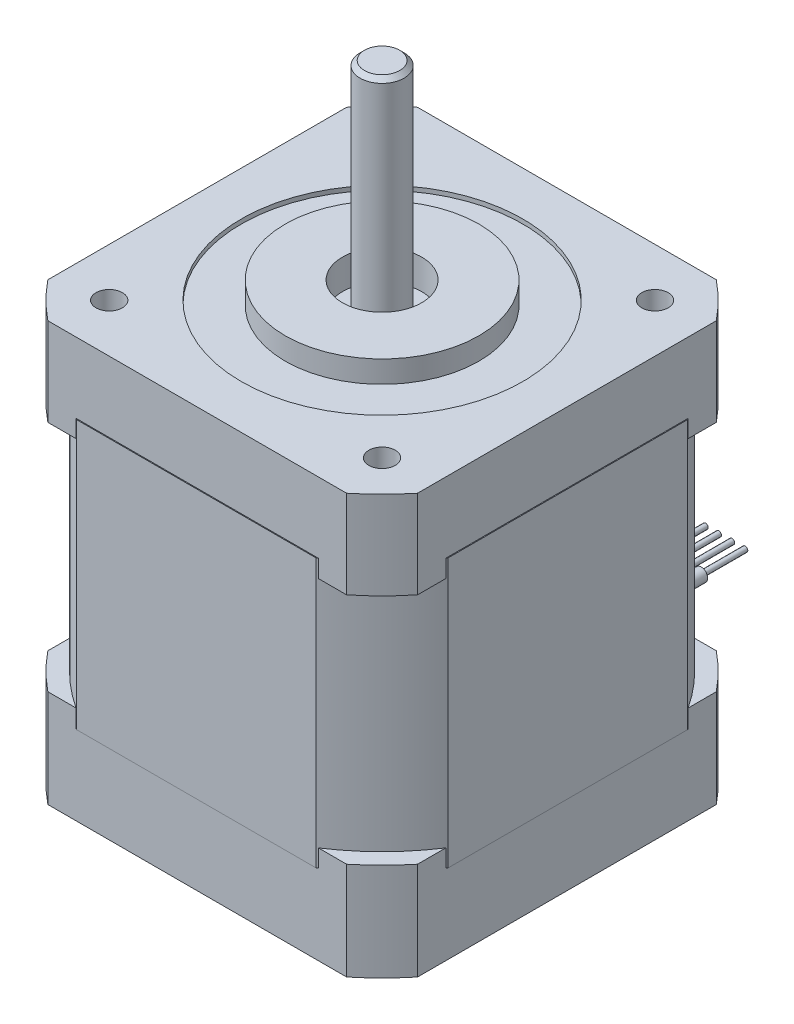
from build123d import *

# Parameters (mm, degrees)
SKETCH_2_R          = 1.5
EXTRUDE_2_DEPTH     = 8
SKETCH_3_R          = 16
CUT_EXTRUDE_1_DEPTH = 0.5
SKETCH_4_R          = 11
EXTRUDE_3_DEPTH     = 2.5
SKETCH_5_R          = 4.5
CUT_EXTRUDE_2_DEPTH = 3.4
SKETCH_6_R          = 2.5
EXTRUDE_4_DEPTH     = 25
CHAMFER_2_SIZE      = 0.5
SKETCH_2_2_R        = 1.5
EXTRUDE_5_DEPTH     = 2
SKETCH_7_R          = 1.5
EXTRUDE_6_DEPTH     = 30.5
SKETCH_8_R          = 1.5
EXTRUDE_8_DEPTH     = 2
SKETCH_8_3_R        = 1.5
EXTRUDE_9_DEPTH     = 9.1
SKETCH_9_R          = 3.5
SKETCH_9_R_2        = 3
CUT_EXTRUDE_3_DEPTH = 3.5
SKETCH_10_R         = 2.5
EXTRUDE_10_DEPTH    = 3
SKETCH_10_2_R       = 2.5
EXTRUDE_11_DEPTH    = 39
FILLET_2_R          = 2
FILLET_3_R          = 2
FILLET_4_R          = 2
FILLET_5_R          = 2
CUT_EXTRUDE_4_DEPTH = 3.5
CUT_EXTRUDE_5_DEPTH = 2
SKETCH_13_R         = 0.74
EXTRUDE_16_DEPTH    = 15
SKETCH_14_R         = 0.3
EXTRUDE_17_DEPTH    = 5


with BuildPart() as part:
    # Sketch 2 → Extrude 2 (new body)
    with BuildSketch(Plane(origin=(0, 0, 0), x_dir=(1, 0, 0), z_dir=(0, 1, 0))):
        with BuildLine():
            Line((16.970562748, 21), (-16.970562748, 21))
            ThreePointArc((-16.970562748, 21), (-19.091883092, 19.091883092), (-21, 16.970562748))
            Line((-21, 16.970562748), (-21, -16.970562748))
            ThreePointArc((-21, -16.970562748), (-19.091883092, -19.091883092), (-16.970562748, -21))
            Line((-16.970562748, -21), (16.970562748, -21))
            ThreePointArc((16.970562748, -21), (19.091883092, -19.091883092), (21, -16.970562748))
            Line((21, -16.970562748), (21, 16.970562748))
            ThreePointArc((21, 16.970562748), (19.091883092, 19.091883092), (16.970562748, 21))
        make_face()
        with Locations((-15.5, 15.5)):
            Circle(SKETCH_2_R, mode=Mode.SUBTRACT)
        with Locations((15.5, 15.5)):
            Circle(SKETCH_2_R, mode=Mode.SUBTRACT)
        with Locations((15.5, -15.5)):
            Circle(SKETCH_2_R, mode=Mode.SUBTRACT)
        with Locations((-15.5, -15.5)):
            Circle(SKETCH_2_R, mode=Mode.SUBTRACT)
    extrude(amount=EXTRUDE_2_DEPTH)

    # Sketch 3 → Cut-Extrude 1 (cut)
    with BuildSketch(Plane(origin=(0, 8, 0), x_dir=(1, 0, 0), z_dir=(0, 1, 0))):
        Circle(SKETCH_3_R)
    extrude(amount=-CUT_EXTRUDE_1_DEPTH, mode=Mode.SUBTRACT)

    # Sketch 4 → Extrude 3 (add)
    with BuildSketch(Plane(origin=(0, 7.5, 0), x_dir=(1, 0, 0), z_dir=(0, 1, 0))):
        Circle(SKETCH_4_R)
    extrude(amount=EXTRUDE_3_DEPTH)

    # Sketch 5 → Cut-Extrude 2 (cut)
    with BuildSketch(Plane(origin=(0, 10, 0), x_dir=(1, 0, 0), z_dir=(0, 1, 0))):
        Circle(SKETCH_5_R)
    extrude(amount=-CUT_EXTRUDE_2_DEPTH, mode=Mode.SUBTRACT)

    # Sketch 6 → Extrude 4 (add)
    with BuildSketch(Plane(origin=(0, 6.6, 0), x_dir=(1, 0, 0), z_dir=(0, 1, 0))):
        Circle(SKETCH_6_R)
    extrude(amount=EXTRUDE_4_DEPTH)

    # Chamfer 2
    chamfer_2_edges = [part.edges().sort_by_distance(p)[0] for p in [
        (-2.5, 31.6, 0),
    ]]
    chamfer(chamfer_2_edges, length=CHAMFER_2_SIZE)

    # Sketch 2_2 → Extrude 5 (add)
    with BuildSketch(Plane(origin=(0, 0, 0), x_dir=(1, 0, 0), z_dir=(0, 1, 0))):
        with BuildLine():
            Line((16.970562748, 21), (-16.970562748, 21))
            ThreePointArc((-16.970562748, 21), (-19.091883092, 19.091883092), (-21, 16.970562748))
            Line((-21, 16.970562748), (-21, -16.970562748))
            ThreePointArc((-21, -16.970562748), (-19.091883092, -19.091883092), (-16.970562748, -21))
            Line((-16.970562748, -21), (16.970562748, -21))
            ThreePointArc((16.970562748, -21), (19.091883092, -19.091883092), (21, -16.970562748))
            Line((21, -16.970562748), (21, 16.970562748))
            ThreePointArc((21, 16.970562748), (19.091883092, 19.091883092), (16.970562748, 21))
        make_face()
        with Locations((-15.5, 15.5)):
            Circle(SKETCH_2_2_R, mode=Mode.SUBTRACT)
        with Locations((15.5, 15.5)):
            Circle(SKETCH_2_2_R, mode=Mode.SUBTRACT)
        with Locations((15.5, -15.5)):
            Circle(SKETCH_2_2_R, mode=Mode.SUBTRACT)
        with Locations((-15.5, -15.5)):
            Circle(SKETCH_2_2_R, mode=Mode.SUBTRACT)
    extrude(amount=-EXTRUDE_5_DEPTH)

    # Sketch 7 → Extrude 6 (add)
    with BuildSketch(Plane(origin=(0, 0, 0), x_dir=(1, 0, 0), z_dir=(0, 1, 0))):
        with BuildLine():
            Line((13.612571396, 21.1), (-13.612571396, 21.1))
            ThreePointArc((-13.612571396, 21.1), (-17.755451276, 17.755451276), (-21.1, 13.612571396))
            Line((-21.1, 13.612571396), (-21.1, -13.612571396))
            ThreePointArc((-21.1, -13.612571396), (-17.755451276, -17.755451276), (-13.612571396, -21.1))
            Line((-13.612571396, -21.1), (13.612571396, -21.1))
            ThreePointArc((13.612571396, -21.1), (17.755451276, -17.755451276), (21.1, -13.612571396))
            Line((21.1, -13.612571396), (21.1, 13.612571396))
            ThreePointArc((21.1, 13.612571396), (17.755451276, 17.755451276), (13.612571396, 21.1))
        make_face()
        with Locations((-15.5, 15.5)):
            Circle(SKETCH_7_R, mode=Mode.SUBTRACT)
        with Locations((15.5, 15.5)):
            Circle(SKETCH_7_R, mode=Mode.SUBTRACT)
        with Locations((-15.5, -15.5)):
            Circle(SKETCH_7_R, mode=Mode.SUBTRACT)
        with Locations((15.5, -15.5)):
            Circle(SKETCH_7_R, mode=Mode.SUBTRACT)
    extrude(amount=-EXTRUDE_6_DEPTH)

    # Sketch 8 → Extrude 8 (add)
    with BuildSketch(Plane.XZ.offset(30.5)):
        with BuildLine():
            Line((16.970562748, 21), (-16.970562748, 21))
            ThreePointArc((-16.970562748, 21), (-19.091883092, 19.091883092), (-21, 16.970562748))
            Line((-21, 16.970562748), (-21, -16.970562748))
            ThreePointArc((-21, -16.970562748), (-19.091883092, -19.091883092), (-16.970562748, -21))
            Line((-16.970562748, -21), (16.970562748, -21))
            ThreePointArc((16.970562748, -21), (19.091883092, -19.091883092), (21, -16.970562748))
            Line((21, -16.970562748), (21, 16.970562748))
            ThreePointArc((21, 16.970562748), (19.091883092, 19.091883092), (16.970562748, 21))
        make_face()
        with Locations((-15.5, 15.5)):
            Circle(SKETCH_8_R, mode=Mode.SUBTRACT)
        with Locations((15.5, 15.5)):
            Circle(SKETCH_8_R, mode=Mode.SUBTRACT)
        with Locations((15.5, -15.5)):
            Circle(SKETCH_8_R, mode=Mode.SUBTRACT)
        with Locations((-15.5, -15.5)):
            Circle(SKETCH_8_R, mode=Mode.SUBTRACT)
    extrude(amount=-EXTRUDE_8_DEPTH)

    # Sketch 8_3 → Extrude 9 (add)
    with BuildSketch(Plane.XZ.offset(30.5)):
        with BuildLine():
            Line((16.970562748, 21), (-16.970562748, 21))
            ThreePointArc((-16.970562748, 21), (-19.091883092, 19.091883092), (-21, 16.970562748))
            Line((-21, 16.970562748), (-21, -16.970562748))
            ThreePointArc((-21, -16.970562748), (-19.091883092, -19.091883092), (-16.970562748, -21))
            Line((-16.970562748, -21), (16.970562748, -21))
            ThreePointArc((16.970562748, -21), (19.091883092, -19.091883092), (21, -16.970562748))
            Line((21, -16.970562748), (21, 16.970562748))
            ThreePointArc((21, 16.970562748), (19.091883092, 19.091883092), (16.970562748, 21))
        make_face()
        with Locations((-15.5, 15.5)):
            Circle(SKETCH_8_3_R, mode=Mode.SUBTRACT)
        with Locations((15.5, 15.5)):
            Circle(SKETCH_8_3_R, mode=Mode.SUBTRACT)
        with Locations((15.5, -15.5)):
            Circle(SKETCH_8_3_R, mode=Mode.SUBTRACT)
        with Locations((-15.5, -15.5)):
            Circle(SKETCH_8_3_R, mode=Mode.SUBTRACT)
    extrude(amount=EXTRUDE_9_DEPTH)

    # Sketch 9 → Cut-Extrude 3 (cut)
    with BuildSketch(Plane.XZ.offset(39.6)):
        Circle(SKETCH_9_R)
        with Locations((-15.5, 15.5)):
            Circle(SKETCH_9_R_2)
        with Locations((15.5, 15.5)):
            Circle(SKETCH_9_R_2)
        with Locations((-15.5, -15.5)):
            Circle(SKETCH_9_R_2)
        with Locations((15.5, -15.5)):
            Circle(SKETCH_9_R_2)
    extrude(amount=-CUT_EXTRUDE_3_DEPTH, mode=Mode.SUBTRACT)

    # Sketch 10 → Extrude 10 (add)
    with BuildSketch(Plane.XZ.offset(36.1)):
        with Locations((15.5, -15.5)):
            Circle(SKETCH_10_R)
        with Locations((15.5, 15.5)):
            Circle(SKETCH_10_R)
        with Locations((-15.5, 15.5)):
            Circle(SKETCH_10_R)
        with Locations((-15.5, -15.5)):
            Circle(SKETCH_10_R)
    extrude(amount=EXTRUDE_10_DEPTH)

    # Sketch 10_2 → Extrude 11 (add)
    with BuildSketch(Plane.XZ.offset(36.1)):
        with Locations((15.5, -15.5)):
            Circle(SKETCH_10_2_R)
        with Locations((15.5, 15.5)):
            Circle(SKETCH_10_2_R)
        with Locations((-15.5, 15.5)):
            Circle(SKETCH_10_2_R)
        with Locations((-15.5, -15.5)):
            Circle(SKETCH_10_2_R)
    extrude(amount=-EXTRUDE_11_DEPTH)

    # Fillet 2
    fillet_2_edges = [part.edges().sort_by_distance(p)[0] for p in [
        (-18, -39.1, -15.5),
    ]]
    fillet(fillet_2_edges, radius=FILLET_2_R)

    # Fillet 3
    fillet_3_edges = [part.edges().sort_by_distance(p)[0] for p in [
        (13, -39.1, -15.5),
    ]]
    fillet(fillet_3_edges, radius=FILLET_3_R)

    # Fillet 4
    fillet_4_edges = [part.edges().sort_by_distance(p)[0] for p in [
        (13, -39.1, 15.5),
    ]]
    fillet(fillet_4_edges, radius=FILLET_4_R)

    # Fillet 5
    fillet_5_edges = [part.edges().sort_by_distance(p)[0] for p in [
        (-18, -39.1, 15.5),
    ]]
    fillet(fillet_5_edges, radius=FILLET_5_R)

    # Sketch 11 → Cut-Extrude 4 (cut)
    with BuildSketch(Plane.XZ.offset(39.6)):
        Polygon((-15.5, 17.1), (-15.2, 17.1), (-15.2, 15.8), (-13.9, 15.8), (-13.9, 15.2), (-15.2, 15.2), (-15.2, 13.9), (-15.8, 13.9), (-15.8, 15.2), (-17.1, 15.2), (-17.1, 15.8), (-15.8, 15.8), (-15.8, 17.1), align=None)
        Polygon((15.8, 17.1), (15.5, 17.1), (15.2, 17.1), (15.2, 15.8), (13.9, 15.8), (13.9, 15.2), (15.2, 15.2), (15.2, 13.9), (15.8, 13.9), (15.8, 15.2), (17.1, 15.2), (17.1, 15.8), (15.8, 15.8), align=None)
        Polygon((15.5, -17.1), (15.2, -17.1), (15.2, -15.8), (13.9, -15.8), (13.9, -15.2), (15.2, -15.2), (15.2, -13.9), (15.8, -13.9), (15.8, -15.2), (17.1, -15.2), (17.1, -15.8), (15.8, -15.8), (15.8, -17.1), align=None)
        Polygon((-15.8, -17.1), (-15.5, -17.1), (-15.2, -17.1), (-15.2, -15.8), (-13.9, -15.8), (-13.9, -15.2), (-15.2, -15.2), (-15.2, -13.9), (-15.8, -13.9), (-15.8, -15.2), (-17.1, -15.2), (-17.1, -15.8), (-15.8, -15.8), align=None)
    extrude(amount=-CUT_EXTRUDE_4_DEPTH, mode=Mode.SUBTRACT)

    # Sketch 12 → Cut-Extrude 5 (cut)
    with BuildSketch(Plane(origin=(0, 0, -21), x_dir=(-1, 0, 0), z_dir=(0, 0, -1))):
        Polygon((0, -35.6), (3, -35.6), (3, -34.1), (-3, -34.1), (-3, -35.6), align=None)
    extrude(amount=-CUT_EXTRUDE_5_DEPTH, mode=Mode.SUBTRACT)

    # Sketch 13 → Extrude 16 (add)
    with BuildSketch(Plane(origin=(0, 0, -19), x_dir=(-1, 0, 0), z_dir=(0, 0, -1))):
        with Locations((-0.75, -34.85)):
            Circle(SKETCH_13_R)
        with Locations((-2.25, -34.85)):
            Circle(SKETCH_13_R)
        with Locations((0.75, -34.85)):
            Circle(SKETCH_13_R)
        with Locations((2.25, -34.85)):
            Circle(SKETCH_13_R)
    extrude(amount=EXTRUDE_16_DEPTH)

    # Sketch 14 → Extrude 17 (add)
    with BuildSketch(Plane(origin=(0, 0, -34), x_dir=(-1, 0, 0), z_dir=(0, 0, -1))):
        with Locations((-2.25, -34.85)):
            Circle(SKETCH_14_R)
        with Locations((-0.75, -34.85)):
            Circle(SKETCH_14_R)
        with Locations((0.75, -34.85)):
            Circle(SKETCH_14_R)
        with Locations((2.25, -34.85)):
            Circle(SKETCH_14_R)
    extrude(amount=EXTRUDE_17_DEPTH)


solid = part.part
